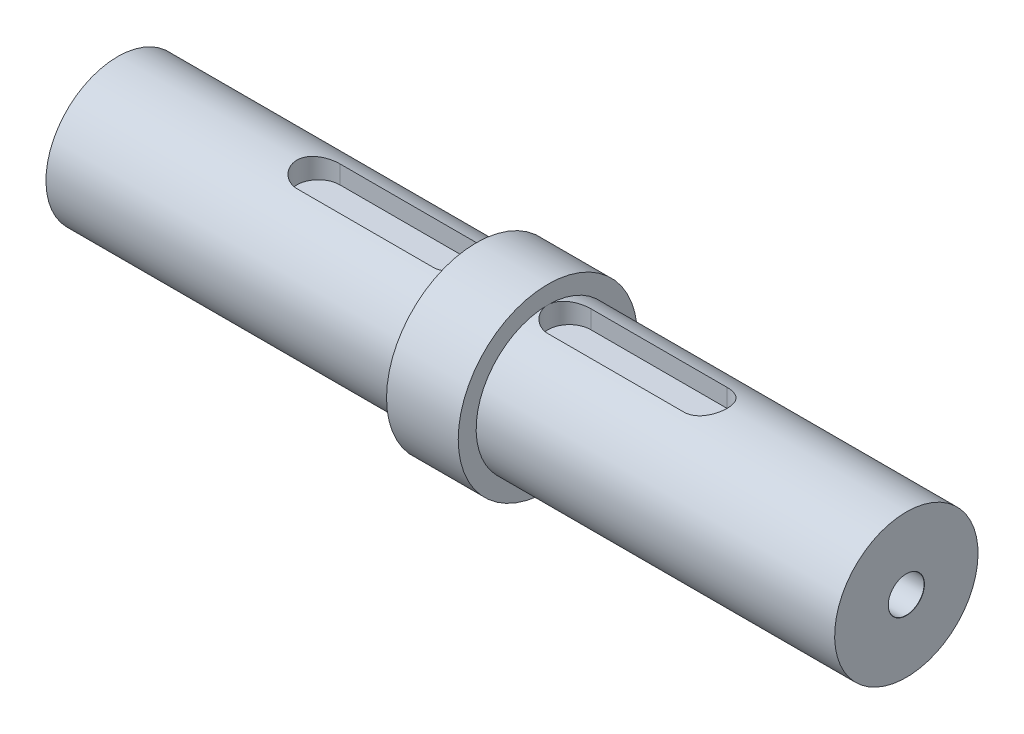
from build123d import *

# Parameters (mm, degrees)
CUT_EXTRUDE1_DEPTH                        = 3
F_5_0MM_DOWEL_HOLE1_D                     = 5
F_5_0MM_DOWEL_HOLE1_DEPTH                 = 10
F_5_0MM_DOWEL_HOLE1_CSINK_D               = 5.05
F_5_0MM_DOWEL_HOLE1_CSINK_ANGLE           = 90
F_5_0MM_DOWEL_HOLE1_TIP                   = 1.502151548
F_5_0MM_DOWEL_HOLE1_ON_FACE_2_D           = 5
F_5_0MM_DOWEL_HOLE1_ON_FACE_2_DEPTH       = 10
F_5_0MM_DOWEL_HOLE1_ON_FACE_2_CSINK_D     = 5.05
F_5_0MM_DOWEL_HOLE1_ON_FACE_2_CSINK_ANGLE = 90
F_5_0MM_DOWEL_HOLE1_ON_FACE_2_TIP         = 1.502151548


with BuildPart() as part:
    # Sketch1 → Revolve1 (revolve)
    with BuildSketch(Plane.XY):
        Polygon((0, 0), (0, 10), (50, 10), (50, 12.5), (60, 12.5), (60, 10), (110, 10), (110, 0), align=None)
    revolve(axis=Axis((110, 0, 0), (-1, 0, 0)))

    # Sketch2 → Cut-Extrude1 (cut)
    with BuildSketch(Plane(origin=(0, 10, 0), x_dir=(1, 0, 0), z_dir=(0, 1, 0))):
        with BuildLine():
            Line((47, -3), (28, -3))
            ThreePointArc((28, -3), (25, 0), (28, 3))
            Line((28, 3), (47, 3))
            ThreePointArc((47, 3), (50, 0), (47, -3))
        make_face()
        with BuildLine():
            Line((63, 3), (82, 3))
            ThreePointArc((82, 3), (85, 0), (82, -3))
            Line((82, -3), (63, -3))
            ThreePointArc((63, -3), (60, 0), (63, 3))
        make_face()
    extrude(amount=-CUT_EXTRUDE1_DEPTH, mode=Mode.SUBTRACT)

    # Ø5.0mm Dowel Hole1
    with Locations(Plane.YZ.offset(110)):
        with Locations((0, 0)):
            CounterSinkHole(F_5_0MM_DOWEL_HOLE1_D / 2, F_5_0MM_DOWEL_HOLE1_CSINK_D / 2, depth=F_5_0MM_DOWEL_HOLE1_DEPTH, counter_sink_angle=F_5_0MM_DOWEL_HOLE1_CSINK_ANGLE)
            with Locations((0, 0, -(F_5_0MM_DOWEL_HOLE1_DEPTH + F_5_0MM_DOWEL_HOLE1_TIP / 2))):  # 118° drill point
                Cone(0, F_5_0MM_DOWEL_HOLE1_D / 2, F_5_0MM_DOWEL_HOLE1_TIP, mode=Mode.SUBTRACT)

    # Ø5.0mm Dowel Hole1 on face 2
    with Locations(Plane(origin=(0, 0, 0), x_dir=(0, 0, -1), z_dir=(-1, 0, 0))):
        with Locations((0, 0)):
            CounterSinkHole(F_5_0MM_DOWEL_HOLE1_ON_FACE_2_D / 2, F_5_0MM_DOWEL_HOLE1_ON_FACE_2_CSINK_D / 2, depth=F_5_0MM_DOWEL_HOLE1_ON_FACE_2_DEPTH, counter_sink_angle=F_5_0MM_DOWEL_HOLE1_ON_FACE_2_CSINK_ANGLE)
            with Locations((0, 0, -(F_5_0MM_DOWEL_HOLE1_ON_FACE_2_DEPTH + F_5_0MM_DOWEL_HOLE1_ON_FACE_2_TIP / 2))):  # 118° drill point
                Cone(0, F_5_0MM_DOWEL_HOLE1_ON_FACE_2_D / 2, F_5_0MM_DOWEL_HOLE1_ON_FACE_2_TIP, mode=Mode.SUBTRACT)


solid = part.part
